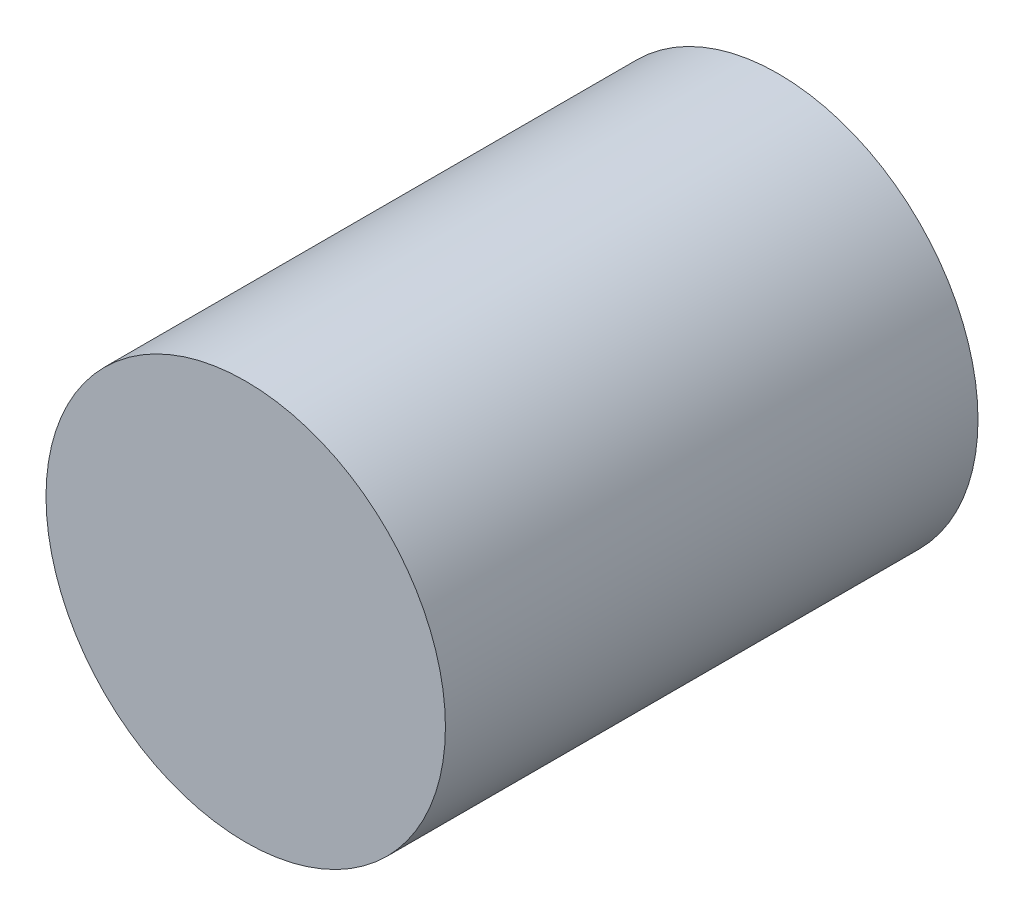
from build123d import *

# Parameters (mm, degrees)
SKETCH1_R           = 1.905
BOSS_EXTRUDE1_DEPTH = 5.08


with BuildPart() as part:
    # Sketch1 → Boss-Extrude1 (new body)
    with BuildSketch(Plane.XY):
        Circle(SKETCH1_R)
    extrude(amount=BOSS_EXTRUDE1_DEPTH)


solid = part.part
